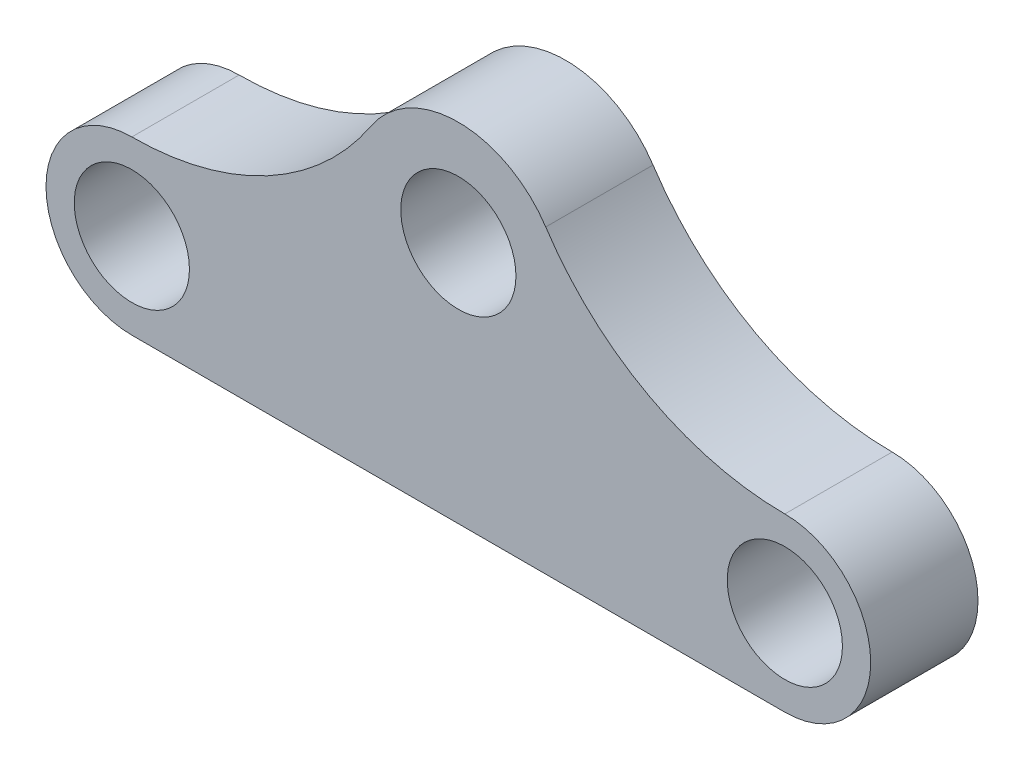
from build123d import *

# Parameters (mm, degrees)
SKETCH1_R           = 4.025
BOSS_EXTRUDE1_DEPTH = 7.5


with BuildPart() as part:
    # Sketch1 → Boss-Extrude1 (new body)
    with BuildSketch(Plane.XY):
        with BuildLine():
            Line((0, -6), (45.64, -6))
            ThreePointArc((45.64, -6), (51.64, 0), (45.64, 6))
            ThreePointArc((45.64, 6), (36.145582493, 8.39727191), (28.927235025, 15.01439638))
            ThreePointArc((28.927235025, 15.01439638), (22.82, 18.308467551), (16.712764975, 15.01439638))
            ThreePointArc((16.712764975, 15.01439638), (9.494417507, 8.39727191), (0, 6))
            ThreePointArc((0, 6), (-6, 0), (0, -6))
        make_face()
        Circle(SKETCH1_R, mode=Mode.SUBTRACT)
        with Locations((45.64, 0)):
            Circle(SKETCH1_R, mode=Mode.SUBTRACT)
        with Locations((22.82, 11)):
            Circle(SKETCH1_R, mode=Mode.SUBTRACT)
    extrude(amount=BOSS_EXTRUDE1_DEPTH)


solid = part.part
